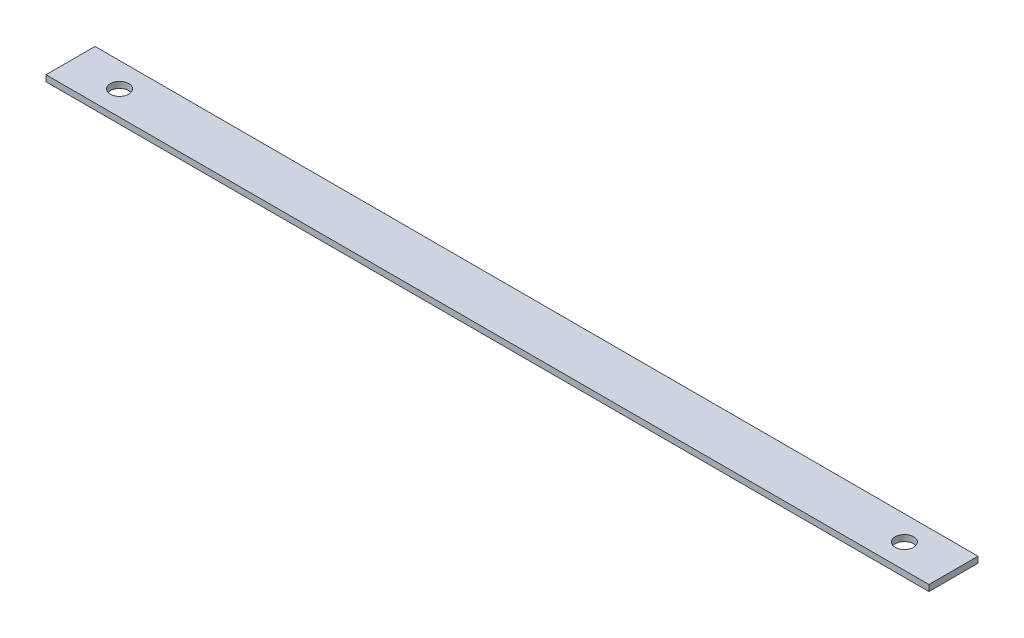
from build123d import *

# Parameters (mm, degrees)
SKETCH1_W           = 457.2
SKETCH1_H           = 25.4
BOSS_EXTRUDE1_DEPTH = 3.175
SKETCH2_R           = 4.7625
CUT_EXTRUDE1_DEPTH  = 4.175


with BuildPart() as part:
    # Sketch1 → Boss-Extrude1 (new body)
    with BuildSketch(Plane(origin=(0, 0, 0), x_dir=(1, 0, 0), z_dir=(0, 1, 0))):
        Rectangle(SKETCH1_W, SKETCH1_H)
    extrude(amount=BOSS_EXTRUDE1_DEPTH)

    # Sketch2 → Cut-Extrude1 (cut, through all)
    with BuildSketch(Plane(origin=(0, 3.175, 0), x_dir=(1, 0, 0), z_dir=(0, 1, 0))):
        with Locations((-203.2, 0)):
            Circle(SKETCH2_R)
        with Locations((203.2, 0)):
            Circle(SKETCH2_R)
    extrude(amount=-CUT_EXTRUDE1_DEPTH, mode=Mode.SUBTRACT)


solid = part.part
